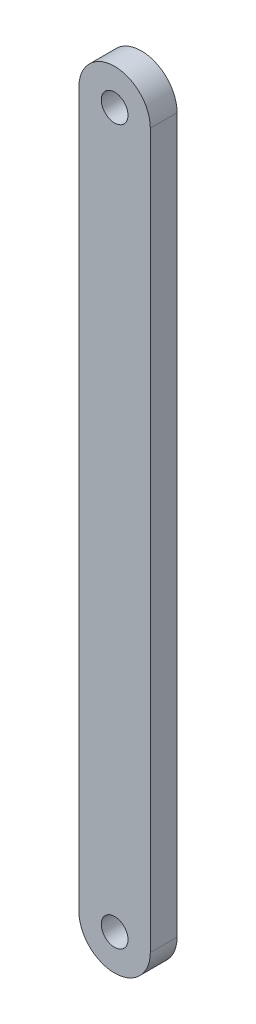
from build123d import *

# Parameters (mm, degrees)
MODEL_R             = 1.5
BOSS_EXTRUDE1_DEPTH = 3


with BuildPart() as part:
    # Model → Boss-Extrude1 (new body)
    with BuildSketch(Plane.XY):
        with BuildLine():
            Line((47.500099999, 80.00015), (47.500099999, 4.9999e-05))
            ThreePointArc((47.500099999, 4.9999e-05), (51.499999999, -3.99985), (55.499899998, 4.9999e-05))
            Line((55.499899998, 4.9999e-05), (55.499899998, 80.000050001))
            ThreePointArc((55.499899998, 80.000050001), (51.500049998, 84), (47.500099999, 80.00015))
        make_face()
        with Locations((51.500099998, 4.9998e-05)):
            Circle(MODEL_R, mode=Mode.SUBTRACT)
        with Locations((51.500099998, 80.000049998)):
            Circle(MODEL_R, mode=Mode.SUBTRACT)
    extrude(amount=BOSS_EXTRUDE1_DEPTH)


solid = part.part
